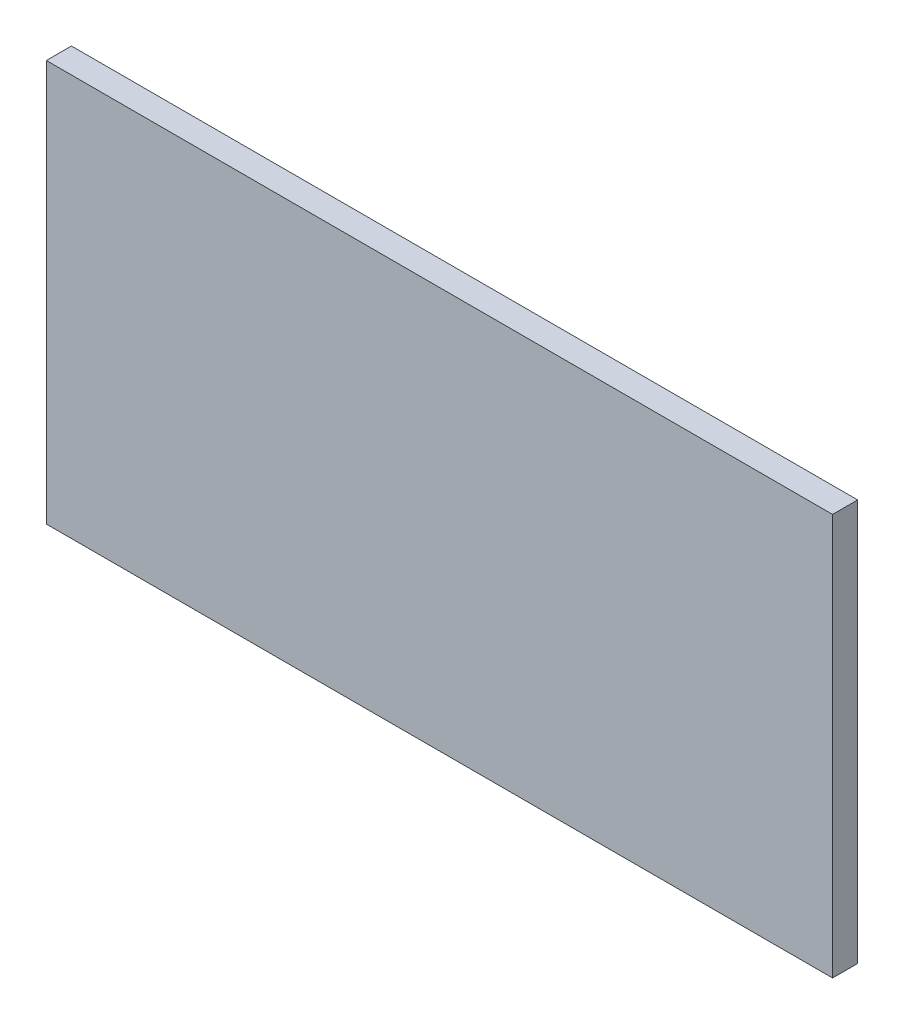
from build123d import *

# Parameters (mm, degrees)
SKETCH1_W           = 564
SKETCH1_H           = 288
BOSS_EXTRUDE1_DEPTH = 18


with BuildPart() as part:
    # Sketch1 → Boss-Extrude1 (new body)
    with BuildSketch(Plane.XY):
        Rectangle(SKETCH1_W, SKETCH1_H)
    extrude(amount=BOSS_EXTRUDE1_DEPTH)


solid = part.part
